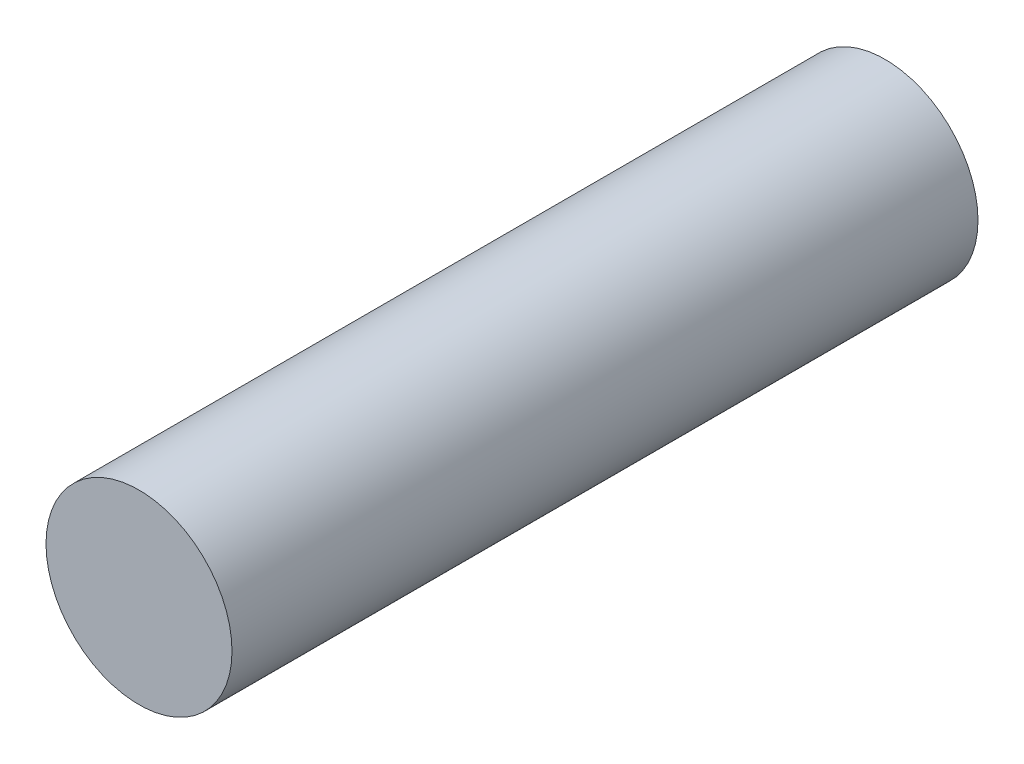
from build123d import *

# Parameters (mm, degrees)
SKETCH2_R           = 2.3749
BOSS_EXTRUDE1_DEPTH = 19.05


with BuildPart() as part:
    # Sketch2 → Boss-Extrude1 (new body)
    with BuildSketch(Plane.XY):
        Circle(SKETCH2_R)
    extrude(amount=BOSS_EXTRUDE1_DEPTH)


solid = part.part
